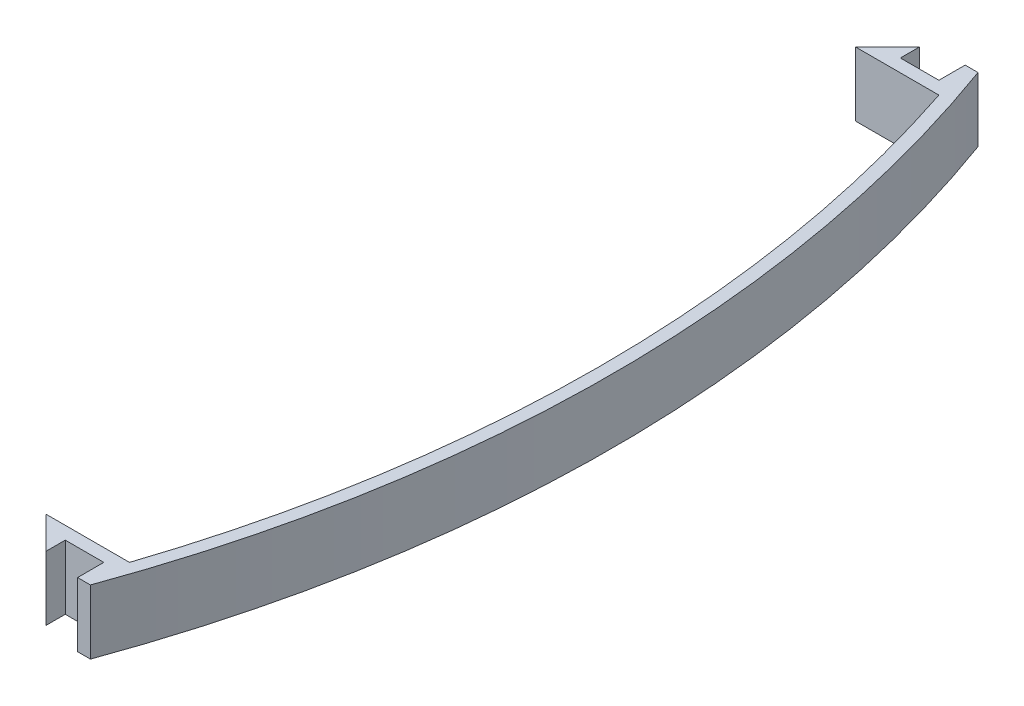
from build123d import *

# Parameters (mm, degrees)
BOSS_EXTRU_1_DEPTH = 10


with BuildPart() as part:
    # Esquisse1 → Boss.-Extru.1 (new body)
    with BuildSketch(Plane(origin=(0, 0, 0), x_dir=(1, 0, 0), z_dir=(0, 1, 0))):
        with BuildLine():
            Line((0, -61), (-13, -61))
            Line((-13, -61), (-8, -66))
            Line((-8, -66), (-8, -63))
            Line((-8, -63), (-2, -63))
            Line((-2, -63), (-2, -67.086901798))
            Line((-2, -67.086901798), (0, -67.086901798))
            ThreePointArc((0, -67.086901798), (12.181665796, 2), (0, 71.086901798))
            Line((0, 71.086901798), (-2, 71.086901798))
            Line((-2, 71.086901798), (-2, 67))
            Line((-2, 67), (-8, 67))
            Line((-8, 67), (-8, 70))
            Line((-8, 70), (-13, 65))
            Line((-13, 65), (0, 65))
            ThreePointArc((0, 65), (10.181665796, 2), (0, -61))
        make_face()
    extrude(amount=BOSS_EXTRU_1_DEPTH)


solid = part.part
